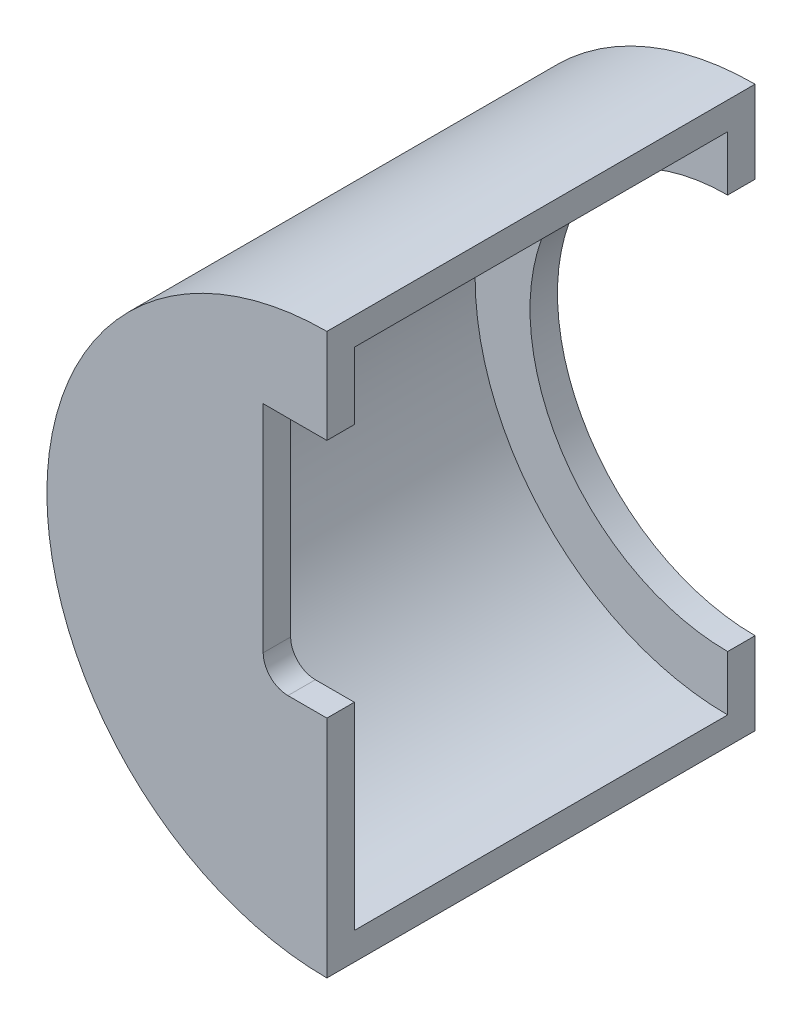
from build123d import *

# Parameters (mm, degrees)
BOSS_EXTRU_1_DEPTH      = 34
BOSS_EXTRU_2_DEPTH      = 5
BOSS_EXTRU_3_DEPTH      = 5
ENL_V_MAT_EXTRU_1_DEPTH = 10


with BuildPart() as part:
    # Esquisse1 → Boss.-Extru.1 (new body, symmetric)
    with BuildSketch(Plane.XY):
        with BuildLine():
            Line((0, 51), (0, 46))
            ThreePointArc((0, 46), (-46, 0), (0, -46))
            Line((0, -46), (0, -51))
            ThreePointArc((0, -51), (-51, 0), (0, 51))
        make_face()
    extrude(amount=BOSS_EXTRU_1_DEPTH, both=True)

    # Esquisse2 → Boss.-Extru.2 (add)
    with BuildSketch(Plane.XY.offset(34)):
        with BuildLine():
            Line((0, 51), (0, -51))
            ThreePointArc((0, -51), (-51, 0), (0, 51))
        make_face()
    extrude(amount=BOSS_EXTRU_2_DEPTH)

    # Esquisse3 → Boss.-Extru.3 (add)
    with BuildSketch(Plane(origin=(0, 0, -34), x_dir=(-1, 0, 0), z_dir=(0, 0, -1))):
        with BuildLine():
            Line((0, 51), (0, 36))
            ThreePointArc((0, 36), (36, 0), (0, -36))
            Line((0, -36), (0, -51))
            ThreePointArc((0, -51), (51, 0), (0, 51))
        make_face()
    extrude(amount=BOSS_EXTRU_3_DEPTH)

    # Esquisse4 → Enlèv. mat.-Extru.1 (cut)
    with BuildSketch(Plane.XY.offset(39)):
        with BuildLine():
            ThreePointArc((0.788986692, -2), (2.15, 0), (0.788986692, 2))
            Line((0.788986692, 2), (11.60000004, 2))
            Line((11.60000004, 2), (11.60000004, 33.8))
            Line((11.60000004, 33.8), (-11.59999996, 33.8))
            Line((-11.59999996, 33.8), (-11.59999996, -5.499999956))
            ThreePointArc((-11.59999996, -5.499999956), (-10.281980449, -8.681980534), (-7.099999871, -10.000000044))
            Line((-7.099999871, -10.000000044), (7.10000004, -10.000000044))
            ThreePointArc((7.10000004, -10.000000044), (10.281980555, -8.68198056), (11.60000004, -5.500000044))
            Line((11.60000004, -5.500000044), (11.60000004, -2))
            Line((11.60000004, -2), (0.788986692, -2))
        make_face()
    extrude(amount=-ENL_V_MAT_EXTRU_1_DEPTH, mode=Mode.SUBTRACT)


solid = part.part
